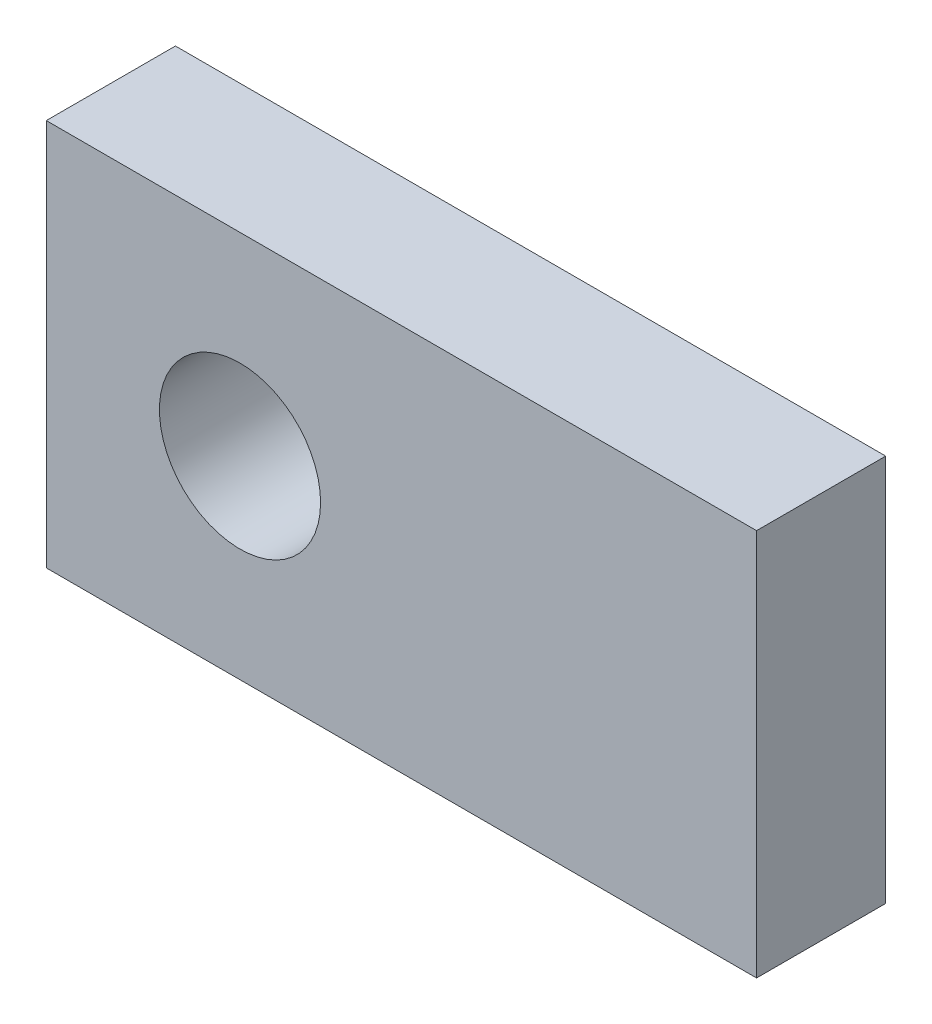
from build123d import *

# Parameters (mm, degrees)
SKETCH1_W           = 34.925
SKETCH1_H           = 19.05
SKETCH1_R           = 3.9624
BOSS_EXTRUDE1_DEPTH = 6.35


with BuildPart() as part:
    # Sketch1 → Boss-Extrude1 (new body)
    with BuildSketch(Plane.XY):
        with Locations((7.9375, 0)):
            Rectangle(SKETCH1_W, SKETCH1_H)
        Circle(SKETCH1_R, mode=Mode.SUBTRACT)
    extrude(amount=BOSS_EXTRUDE1_DEPTH)


solid = part.part
